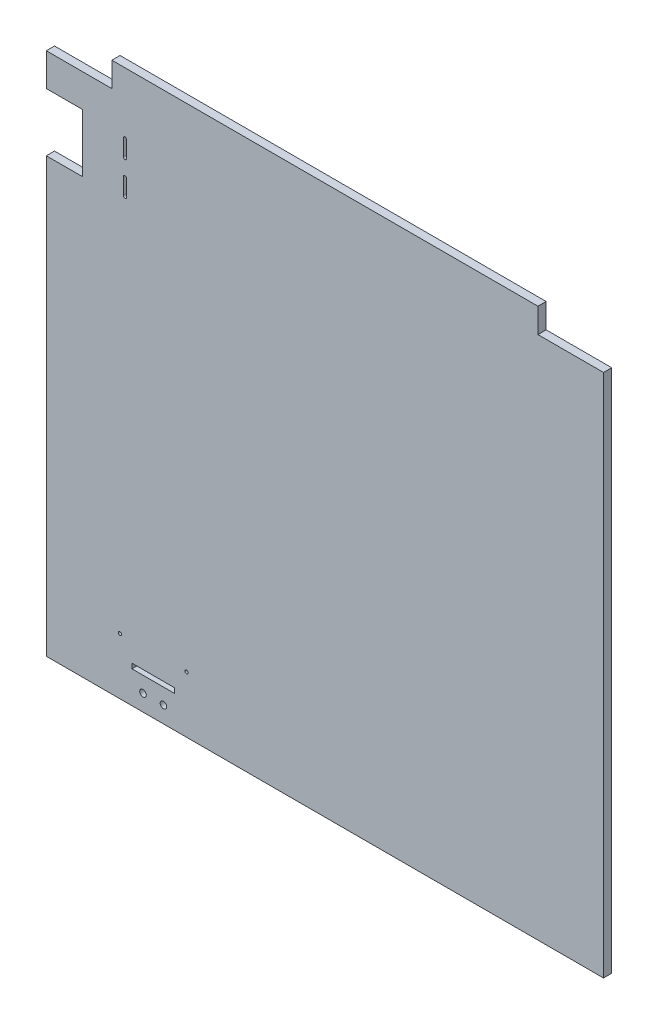
from build123d import *

# Parameters (mm, degrees)
ESQUISSE1_W             = 680
ESQUISSE1_H             = 670
BOSS_EXTRU_1_DEPTH      = 10
ESQUISSE2_W             = 80
ESQUISSE2_H             = 30
ENL_V_MAT_EXTRU_1_DEPTH = 11
ESQUISSE3_W             = 52
ESQUISSE3_H             = 6
ENL_V_MAT_EXTRU_2_DEPTH = 11
ESQUISSE4_R             = 4
ENL_V_MAT_EXTRU_3_DEPTH = 11
ESQUISSE5_R             = 2
ENL_V_MAT_EXTRU_4_DEPTH = 11
ESQUISSE6_W             = 44
ESQUISSE6_H             = 71
ENL_V_MAT_EXTRU_5_DEPTH = 11
ENL_V_MAT_EXTRU_6_DEPTH = 11


with BuildPart() as part:
    # Esquisse1 → Boss.-Extru.1 (new body)
    with BuildSketch(Plane.XY):
        Rectangle(ESQUISSE1_W, ESQUISSE1_H)
    extrude(amount=BOSS_EXTRU_1_DEPTH)

    # Esquisse2 → Enlèv. mat.-Extru.1 (cut, through all)
    with BuildSketch(Plane.XY.offset(10)):
        with Locations((-300, 320)):
            Rectangle(ESQUISSE2_W, ESQUISSE2_H)
        with Locations((300, 320)):
            Rectangle(ESQUISSE2_W, ESQUISSE2_H)
    extrude(amount=-ENL_V_MAT_EXTRU_1_DEPTH, mode=Mode.SUBTRACT)

    # Esquisse3 → Enlèv. mat.-Extru.2 (cut, through all)
    with BuildSketch(Plane.XY.offset(10)):
        with Locations((-209.5, -293)):
            Rectangle(ESQUISSE3_W, ESQUISSE3_H)
    extrude(amount=-ENL_V_MAT_EXTRU_2_DEPTH, mode=Mode.SUBTRACT)

    # Esquisse4 → Enlèv. mat.-Extru.3 (cut, through all)
    with BuildSketch(Plane.XY.offset(10)):
        with Locations((-222, -315)):
            Circle(ESQUISSE4_R)
        with Locations((-197, -315)):
            Circle(ESQUISSE4_R)
    extrude(amount=-ENL_V_MAT_EXTRU_3_DEPTH, mode=Mode.SUBTRACT)

    # Esquisse5 → Enlèv. mat.-Extru.4 (cut, through all)
    with BuildSketch(Plane.XY.offset(10)):
        with Locations((-250, -266)):
            Circle(ESQUISSE5_R)
        with Locations((-169, -266)):
            Circle(ESQUISSE5_R)
    extrude(amount=-ENL_V_MAT_EXTRU_4_DEPTH, mode=Mode.SUBTRACT)

    # Esquisse6 → Enlèv. mat.-Extru.5 (cut, through all)
    with BuildSketch(Plane.XY.offset(10)):
        with Locations((-318, 229.5)):
            Rectangle(ESQUISSE6_W, ESQUISSE6_H)
    extrude(amount=-ENL_V_MAT_EXTRU_5_DEPTH, mode=Mode.SUBTRACT)

    # Esquisse7 → Enlèv. mat.-Extru.6 (cut, through all)
    with BuildSketch(Plane.XY.offset(10)):
        with BuildLine():
            Line((-246, 260), (-246, 240))
            ThreePointArc((-246, 240), (-244, 238), (-242, 240))
            Line((-242, 240), (-242, 260))
            ThreePointArc((-242, 260), (-244, 262), (-246, 260))
        make_face()
        with BuildLine():
            Line((-246, 219), (-246, 199))
            ThreePointArc((-246, 199), (-244, 197), (-242, 199))
            Line((-242, 199), (-242, 219))
            ThreePointArc((-242, 219), (-244, 221), (-246, 219))
        make_face()
    extrude(amount=-ENL_V_MAT_EXTRU_6_DEPTH, mode=Mode.SUBTRACT)


solid = part.part
